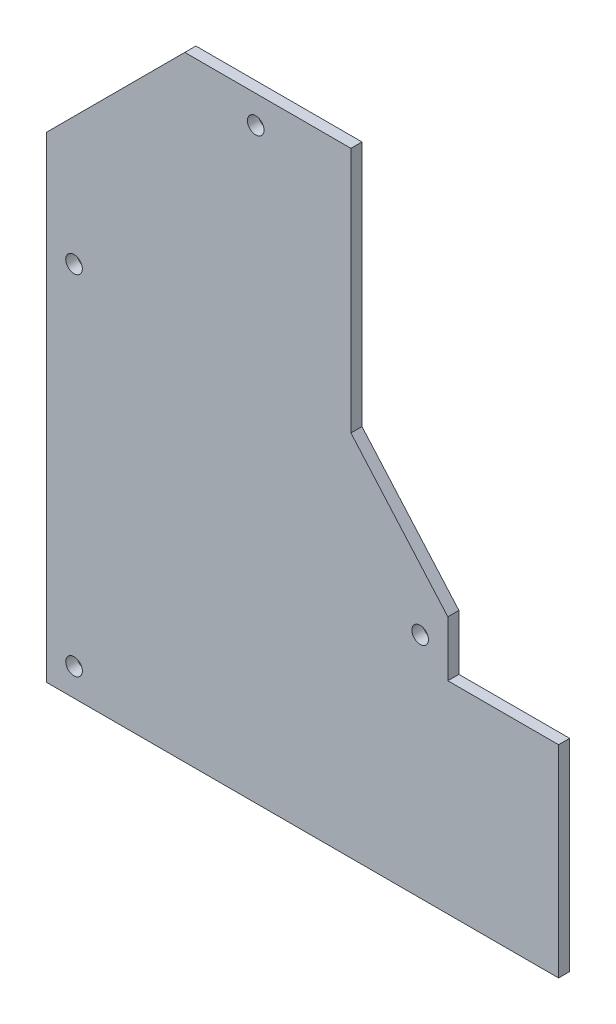
from build123d import *

# Parameters (mm, degrees)
EXTRUDE_1_DEPTH     = 4
SKETCH_2_R          = 3
CUT_EXTRUDE_1_DEPTH = 10


with BuildPart() as part:
    # 草图1 → 凸台-拉伸1 (new body)
    with BuildSketch(Plane.XY):
        Polygon((-85, -75), (100, -75), (100, -2.031815791), (60, -2.031815791), (60, 17.968184209), (25, 57.968184209), (25, 147), (-35, 147), (-85, 97), align=None)
    extrude(amount=EXTRUDE_1_DEPTH)

    # 草图2 → 切除-拉伸1 (cut)
    with BuildSketch(Plane(origin=(0, 0, 0), x_dir=(-1, 0, 0), z_dir=(0, 0, -1))):
        with Locations((75, -65)):
            Circle(SKETCH_2_R)
        with Locations((-50, 7.332157467)):
            Circle(SKETCH_2_R)
        with Locations((9.393398282, 137)):
            Circle(SKETCH_2_R)
        with Locations((75, 60.786796564)):
            Circle(SKETCH_2_R)
    extrude(amount=-CUT_EXTRUDE_1_DEPTH, mode=Mode.SUBTRACT)


solid = part.part
